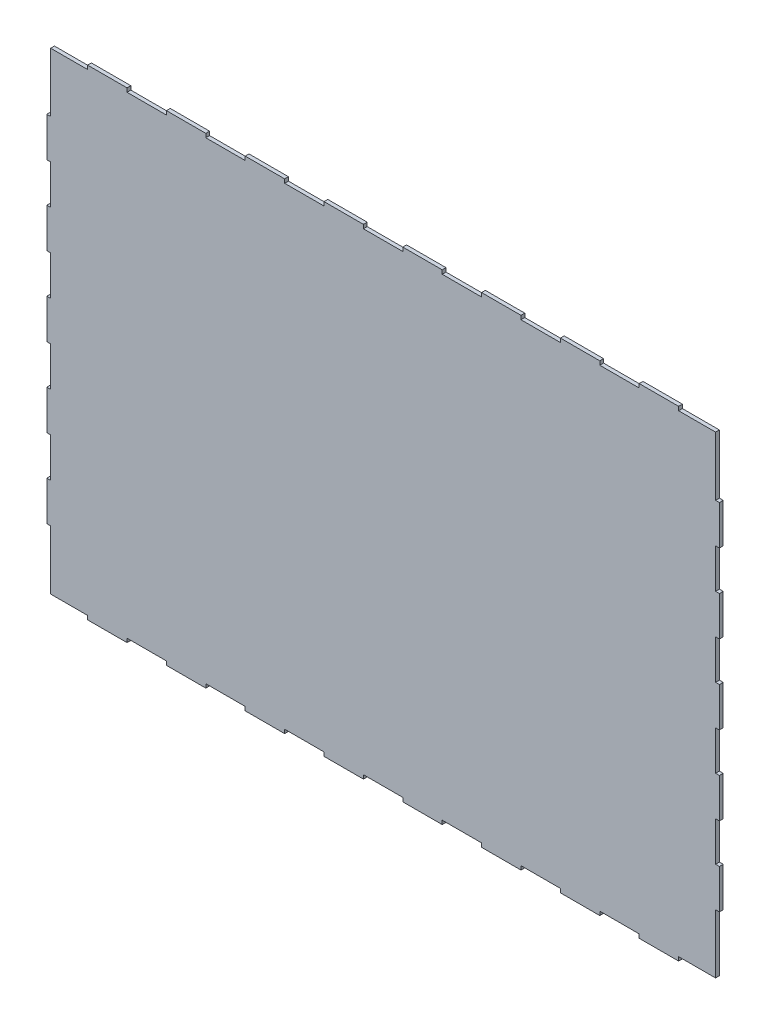
from build123d import *

# Parameters (mm, degrees)
BOSS_EXTRUDE1_DEPTH = 50
SCALE1_SCALE        = 0.04


with BuildPart() as part:
    # Sketch1 → Boss-Extrude1 (new body)
    with BuildSketch(Plane.XY):
        Polygon((-1.484062936, 0.145079086), (487.465937064, 0.145079086), (487.465937064, -50.654920914), (1008.165937064, -50.654920914), (1008.165937064, 0.145079086), (1528.865937064, 0.145079086), (1528.865937064, -50.654920914), (2049.565937064, -50.654920914), (2049.565937064, 0.145079086), (2570.265937064, 0.145079086), (2570.265937064, -50.654920914), (3090.965937064, -50.654920914), (3090.965937064, 0.145079086), (3611.665937064, 0.145079086), (3611.665937064, -50.654920914), (4132.365937064, -50.654920914), (4132.365937064, 0.145079086), (4653.065937064, 0.145079086), (4653.065937064, -50.654920914), (5173.765937064, -50.654920914), (5173.765937064, 0.145079086), (5694.465937064, 0.145079086), (5694.465937064, -50.654920914), (6215.165937064, -50.654920914), (6215.165937064, 0.145079086), (6735.865937064, 0.145079086), (6735.865937064, -50.654920914), (7256.565937064, -50.654920914), (7256.565937064, 0.145079086), (7777.265937064, 0.145079086), (7777.265937064, -50.654920914), (8297.965937064, -50.654920914), (8297.965937064, 0.145079086), (8786.915937064, 0.145079086), (8786.915937064, 781.195079086), (8837.715937064, 781.195079086), (8837.715937064, 1301.895079086), (8786.915937064, 1301.895079086), (8786.915937064, 1822.595079086), (8837.715937064, 1822.595079086), (8837.715937064, 2343.295079086), (8786.915937064, 2343.295079086), (8786.915937064, 2863.995079086), (8837.715937064, 2863.995079086), (8837.715937064, 3384.695079086), (8786.915937064, 3384.695079086), (8786.915937064, 3905.395079086), (8837.715937064, 3905.395079086), (8837.715937064, 4426.095079086), (8786.915937064, 4426.095079086), (8786.915937064, 4946.795079086), (8837.715937064, 4946.795079086), (8837.715937064, 5467.495079086), (8786.915937064, 5467.495079086), (8786.915937064, 5988.195079086), (8786.915937064, 6248.545079086), (8297.965937064, 6248.545079086), (8297.965937064, 6299.345079086), (7777.265937064, 6299.345079086), (7777.265937064, 6248.545079086), (7256.565937064, 6248.545079086), (7256.565937064, 6299.345079086), (6735.865937064, 6299.345079086), (6735.865937064, 6248.545079086), (6215.165937064, 6248.545079086), (6215.165937064, 6299.345079086), (5694.465937064, 6299.345079086), (5694.465937064, 6248.545079086), (5173.765937064, 6248.545079086), (5173.765937064, 6299.345079086), (4653.065937064, 6299.345079086), (4653.065937064, 6248.545079086), (4132.365937064, 6248.545079086), (4132.365937064, 6299.345079086), (3611.665937064, 6299.345079086), (3611.665937064, 6248.545079086), (3090.965937064, 6248.545079086), (3090.965937064, 6299.345079086), (2570.265937064, 6299.345079086), (2570.265937064, 6248.545079086), (2049.565937064, 6248.545079086), (2049.565937064, 6299.345079086), (1528.865937064, 6299.345079086), (1528.865937064, 6248.545079086), (1008.165937064, 6248.545079086), (1008.165937064, 6299.345079086), (487.465937064, 6299.345079086), (487.465937064, 6248.545079086), (-1.484062936, 6248.545079086), (-1.484062936, 5467.495079086), (-52.284062936, 5467.495079086), (-52.284062936, 4946.795079086), (-1.484062936, 4946.795079086), (-1.484062936, 4426.095079086), (-52.284062936, 4426.095079086), (-52.284062936, 3905.395079086), (-1.484062936, 3905.395079086), (-1.484062936, 3384.695079086), (-52.284062936, 3384.695079086), (-52.284062936, 2863.995079086), (-1.484062936, 2863.995079086), (-1.484062936, 2343.295079086), (-52.284062936, 2343.295079086), (-52.284062936, 1822.595079086), (-1.484062936, 1822.595079086), (-1.484062936, 1301.895079086), (-52.284062936, 1301.895079086), (-52.284062936, 781.195079086), (-1.484062936, 781.195079086), (-1.484062936, 260.495079086), align=None)
    extrude(amount=BOSS_EXTRUDE1_DEPTH)


with BuildPart() as part_1:
    # Scale1: scaled about (4392.715937064, 3124.345079086, 25)
    add(part.part.scale(SCALE1_SCALE).moved(Location((4217.007299581, 2999.371275923, 24))))


solid = part_1.part
